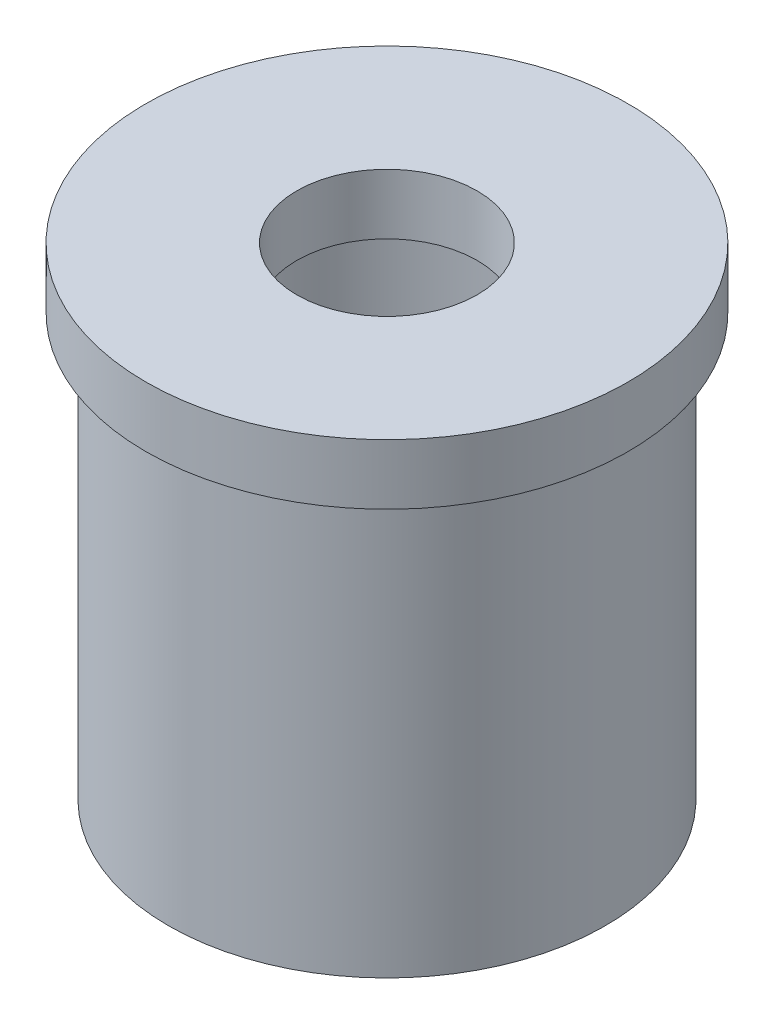
from build123d import *

# Parameters (mm, degrees)
SKETCH1_R                        = 23.01875
BOSS_EXTRUDE1_DEPTH              = 44.45
SKETCH2_R                        = 25.4
BOSS_EXTRUDE2_DEPTH              = 6.35
SKETCH3_R                        = 9.5
CUT_EXTRUDE1_DEPTH               = 63.217039467
SKETCH4_R                        = 16.6751
CUT_EXTRUDE2_DEPTH               = 44.45
SKETCH5_R                        = 1.5875
CUT_EXTRUDE3_DEPTH               = 19.05
TAP_DRILL_FOR_1_4_20_TAP1_REACH  = 76.634
TAP_DRILL_FOR_1_4_20_TAP1_BORE_R = 2.5527


with BuildPart() as part:
    # Sketch1 → Boss-Extrude1 (new body)
    with BuildSketch(Plane(origin=(0, 0, 0), x_dir=(1, 0, 0), z_dir=(0, 1, 0))):
        with Locations(Location((0, 0, 0), (0, 0, 270))):
            Circle(SKETCH1_R)
    extrude(amount=BOSS_EXTRUDE1_DEPTH)

    # Sketch2 → Boss-Extrude2 (add)
    with BuildSketch(Plane(origin=(0, 44.45, 0), x_dir=(1, 0, 0), z_dir=(0, 1, 0))):
        with Locations(Location((0, 0, 0), (0, 0, 270))):
            Circle(SKETCH2_R)
    extrude(amount=BOSS_EXTRUDE2_DEPTH)

    # Sketch3 → Cut-Extrude1 (cut, through all)
    with BuildSketch(Plane(origin=(0, 50.8, 0), x_dir=(1, 0, 0), z_dir=(0, 1, 0))):
        with Locations(Location((0, 0, 0), (0, 0, 270))):
            Circle(SKETCH3_R)
    extrude(amount=-CUT_EXTRUDE1_DEPTH, mode=Mode.SUBTRACT)

    # Sketch4 → Cut-Extrude2 (cut)
    with BuildSketch(Plane.XZ):
        with Locations(Location((0, 0, 0), (0, 0, 270))):
            Circle(SKETCH4_R)
    extrude(amount=-CUT_EXTRUDE2_DEPTH, mode=Mode.SUBTRACT)

    # Sketch5 → Cut-Extrude3 (cut)
    with BuildSketch(Plane.XZ):
        with Locations(Location((19.84375, 0, 0), (0, 0, 270))):
            Circle(SKETCH5_R)
        with Locations(Location((9.921875, -17.185191606, 0), (0, 0, 270))):
            Circle(SKETCH5_R)
        with Locations(Location((-9.921875, -17.185191606, 0), (0, 0, 270))):
            Circle(SKETCH5_R)
        with Locations(Location((-19.84375, 0, 0), (0, 0, 270))):
            Circle(SKETCH5_R)
        with Locations(Location((-9.921875, 17.185191606, 0), (0, 0, 270))):
            Circle(SKETCH5_R)
        with Locations(Location((9.921875, 17.185191606, 0), (0, 0, 270))):
            Circle(SKETCH5_R)
    extrude(amount=-CUT_EXTRUDE3_DEPTH, mode=Mode.SUBTRACT)

    # Tap Drill for 1/4-20 Tap1 bore → Tap Drill for 1/4-20 Tap1 (cut, up to next)
    with BuildSketch(Plane.ZY.offset(23.01875), mode=Mode.PRIVATE) as tap_drill_for_1_4_20_tap1_sk1:
        with Locations((0, 31.75)):
            Circle(TAP_DRILL_FOR_1_4_20_TAP1_BORE_R)
    tap_drill_for_1_4_20_tap1_tool1 = extrude(tap_drill_for_1_4_20_tap1_sk1.sketch, amount=-TAP_DRILL_FOR_1_4_20_TAP1_REACH, mode=Mode.PRIVATE) & part.part
    add(tap_drill_for_1_4_20_tap1_tool1.solids().sort_by_distance((-23.01875, 31.75, 0))[0], mode=Mode.SUBTRACT)


solid = part.part
